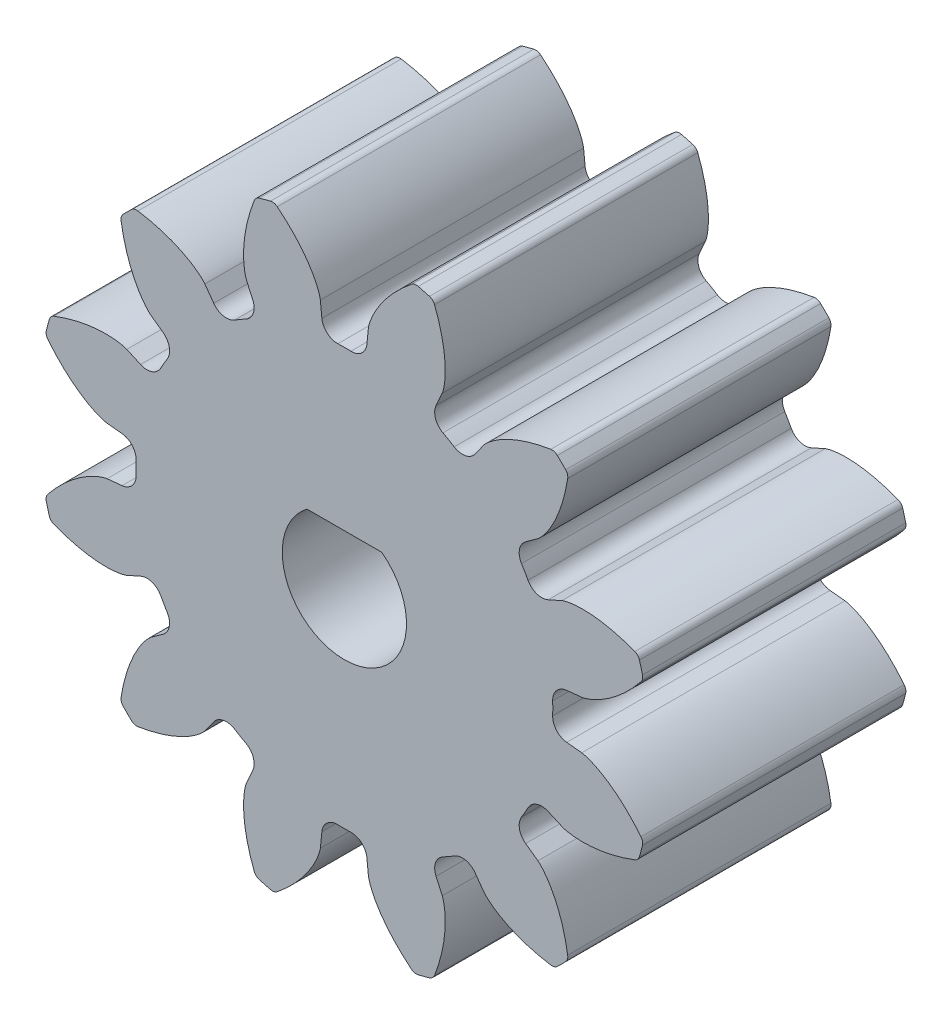
from build123d import *

# Parameters (mm, degrees)
SKETCH1_R                                 = 14.816666667
BOSS_EXTRUDE1_DEPTH                       = 12.7
CUT_EXTRUDE_DCLTBC_DEPTH                  = 13.7
FILLET_TIP_DCLTBC_R                       = 0.376401082
FILLET_ROOT_DCLTBC_R                      = 0.752802164
CIRPATTERN_DCLTBC_COUNT                   = 12
FILLET_TIP_DCLTBC_OF_CIRPATTERN_DCLTBC_R  = 0.376401082
FILLET_ROOT_DCLTBC_OF_CIRPATTERN_DCLTBC_R = 0.752802164
CUT_EXTRUDE5_DEPTH                        = 25.4


with BuildPart() as part:
    # Sketch1 → Boss-Extrude1 (new body)
    with BuildSketch(Plane.XY):
        Circle(SKETCH1_R)
    extrude(amount=BOSS_EXTRUDE1_DEPTH)

    # DCLTBC → Cut-Extrude-DCLTBC (cut, through all)
    with BuildSketch(Plane.XY):
        with BuildLine():
            Line((-1.159679207, 11.451539238), (-1.012988507, 10.003005631))
            ThreePointArc((-1.012988507, 10.003005631), (0, 10.054166667), (1.012988507, 10.003005631))
            Line((1.012988507, 10.003005631), (1.159679207, 11.451539238))
            add(Edge.make_bspline(
                [(1.159679207, 11.451539238), (1.160337964, 11.457092478), (1.162480311, 11.472631127), (1.16769301, 11.501852629), (1.177840848, 11.54925506), (1.1931747, 11.609197723), (1.21573605, 11.686066999), (1.245818813, 11.775761095), (1.282522681, 11.873332486), (1.326352157, 11.978305592), (1.373497508, 12.081909898), (1.423679567, 12.18414424), (1.476494051, 12.284932541), (1.543771073, 12.405699193), (1.629012992, 12.548625234), (1.735198724, 12.712740443), (1.86328375, 12.895246432), (2.001834622, 13.077104839), (2.144700841, 13.252557922), (2.296370835, 13.425560045), (2.448300114, 13.589903271), (2.613368384, 13.755933092), (2.769451673, 13.906830615), (2.95211403, 14.070449823), (3.101823771, 14.200925446), (3.262800626, 14.330996333), (3.342073731, 14.39359933), (3.382973257, 14.425293864)],
                knots=[0, 0, 0, 0, 0, 0.005376749, 0.015083688, 0.02853182, 0.046610139, 0.064854849, 0.092110525, 0.119476176, 0.146842496, 0.174208854, 0.201574955, 0.228941013, 0.256307345, 0.307035032, 0.361767352, 0.41649966, 0.471231936, 0.525964282, 0.580696615, 0.635428982, 0.690161387, 0.744893688, 0.799626082, 0.854358408, 0.909090915, 0.909090915, 0.909090915, 0.909090915, 0.909090915], degree=4))
            ThreePointArc((3.382973257, 14.425293864), (0, 14.816666667), (-3.382973257, 14.425293864))
            add(Edge.make_bspline(
                [(-1.159679207, 11.451539238), (-1.160337964, 11.457092478), (-1.162480311, 11.472631127), (-1.16769301, 11.501852629), (-1.177840848, 11.54925506), (-1.1931747, 11.609197723), (-1.21573605, 11.686066999), (-1.245818813, 11.775761095), (-1.282522681, 11.873332486), (-1.326352157, 11.978305592), (-1.373497508, 12.081909898), (-1.423679567, 12.18414424), (-1.476494051, 12.284932541), (-1.543771073, 12.405699193), (-1.629012992, 12.548625234), (-1.735198724, 12.712740443), (-1.86328375, 12.895246432), (-2.001834622, 13.077104839), (-2.144700841, 13.252557922), (-2.296370835, 13.425560045), (-2.448300114, 13.589903271), (-2.613368384, 13.755933092), (-2.769451673, 13.906830615), (-2.95211403, 14.070449823), (-3.101823771, 14.200925446), (-3.262800626, 14.330996333), (-3.342073731, 14.39359933), (-3.382973257, 14.425293864)],
                knots=[0, 0, 0, 0, 0, 0.005376749, 0.015083688, 0.02853182, 0.046610139, 0.064854849, 0.092110525, 0.119476176, 0.146842496, 0.174208854, 0.201574955, 0.228941013, 0.256307345, 0.307035032, 0.361767352, 0.41649966, 0.471231936, 0.525964282, 0.580696615, 0.635428982, 0.690161387, 0.744893688, 0.799626082, 0.854358408, 0.909090915, 0.909090915, 0.909090915, 0.909090915, 0.909090915], degree=4))
        make_face()
    cut_extrude_dcltbc = extrude(amount=CUT_EXTRUDE_DCLTBC_DEPTH, mode=Mode.SUBTRACT)

    # Fillet-Tip-DCLTBC
    fillet_tip_dcltbc_edges = [part.edges().sort_by_distance(p)[0] for p in [
        (3.382973257, 14.425293864, 6.35),
        (-3.382973257, 14.425293864, 6.35),
    ]]
    fillet(fillet_tip_dcltbc_edges, radius=FILLET_TIP_DCLTBC_R)

    # Fillet-Root-DCLTBC
    fillet_root_dcltbc_edges = [part.edges().sort_by_distance(p)[0] for p in [
        (1.012988507, 10.003005631, 6.35),
        (-1.012988507, 10.003005631, 6.35),
    ]]
    fillet(fillet_root_dcltbc_edges, radius=FILLET_ROOT_DCLTBC_R)

    # CirPattern-DCLTBC: Cut-Extrude-DCLTBC ×12 about axis
    cirpattern_dcltbc_axis = Axis((0, 0, 12.7), (0, 0, 1))
    for i in range(1, CIRPATTERN_DCLTBC_COUNT):
        add(cut_extrude_dcltbc.rotate(cirpattern_dcltbc_axis, i * 360 / CIRPATTERN_DCLTBC_COUNT), mode=Mode.SUBTRACT)

    # Fillet-Tip-DCLTBC of CirPattern-DCLTBC
    fillet_tip_dcltbc_of_cirpattern_dcltbc_edges = [part.edges().sort_by_distance(p)[0] for p in [
        (-4.282906151, 14.184157571, 6.35),
        (-10.142387713, 10.801184315, 6.35),
        (-10.801184315, 10.142387713, 6.35),
        (-14.184157571, 4.282906151, 6.35),
        (-14.425293864, 3.382973257, 6.35),
        (-14.425293864, -3.382973257, 6.35),
        (-14.184157571, -4.282906151, 6.35),
        (-10.801184315, -10.142387713, 6.35),
        (-10.142387713, -10.801184315, 6.35),
        (-4.282906151, -14.184157571, 6.35),
        (-3.382973257, -14.425293864, 6.35),
        (3.382973257, -14.425293864, 6.35),
        (4.282906151, -14.184157571, 6.35),
        (10.142387713, -10.801184315, 6.35),
        (10.801184315, -10.142387713, 6.35),
        (14.184157571, -4.282906151, 6.35),
        (14.425293864, -3.382973257, 6.35),
        (14.425293864, 3.382973257, 6.35),
        (14.184157571, 4.282906151, 6.35),
        (10.801184315, 10.142387713, 6.35),
        (10.142387713, 10.801184315, 6.35),
        (4.282906151, 14.184157571, 6.35),
    ]]
    fillet(fillet_tip_dcltbc_of_cirpattern_dcltbc_edges, radius=FILLET_TIP_DCLTBC_OF_CIRPATTERN_DCLTBC_R)

    # Fillet-Root-DCLTBC of CirPattern-DCLTBC
    fillet_root_dcltbc_of_cirpattern_dcltbc_edges = [part.edges().sort_by_distance(p)[0] for p in [
        (-4.124229035, 9.169351244, 6.35),
        (-5.878776596, 8.156362737, 6.35),
        (-8.156362737, 5.878776596, 6.35),
        (-9.169351244, 4.124229035, 6.35),
        (-10.003005631, 1.012988507, 6.35),
        (-10.003005631, -1.012988507, 6.35),
        (-9.169351244, -4.124229035, 6.35),
        (-8.156362737, -5.878776596, 6.35),
        (-5.878776596, -8.156362737, 6.35),
        (-4.124229035, -9.169351244, 6.35),
        (-1.012988507, -10.003005631, 6.35),
        (1.012988507, -10.003005631, 6.35),
        (4.124229035, -9.169351244, 6.35),
        (5.878776596, -8.156362737, 6.35),
        (8.156362737, -5.878776596, 6.35),
        (9.169351244, -4.124229035, 6.35),
        (10.003005631, -1.012988507, 6.35),
        (10.003005631, 1.012988507, 6.35),
        (9.169351244, 4.124229035, 6.35),
        (8.156362737, 5.878776596, 6.35),
        (5.878776596, 8.156362737, 6.35),
        (4.124229035, 9.169351244, 6.35),
    ]]
    fillet(fillet_root_dcltbc_of_cirpattern_dcltbc_edges, radius=FILLET_ROOT_DCLTBC_OF_CIRPATTERN_DCLTBC_R)

    # Sketch8 → Cut-Extrude5 (cut)
    with BuildSketch(Plane.XY):
        with BuildLine():
            Line((1.8034, 2.393941578), (-1.8034, 2.393941578))
            ThreePointArc((-1.8034, 2.393941578), (-1.337545767, -2.682196704), (2.9972, 0))
            ThreePointArc((2.9972, 0), (2.682196704, 1.337545767), (1.8034, 2.393941578))
        make_face()
    extrude(amount=CUT_EXTRUDE5_DEPTH, mode=Mode.SUBTRACT)


solid = part.part
